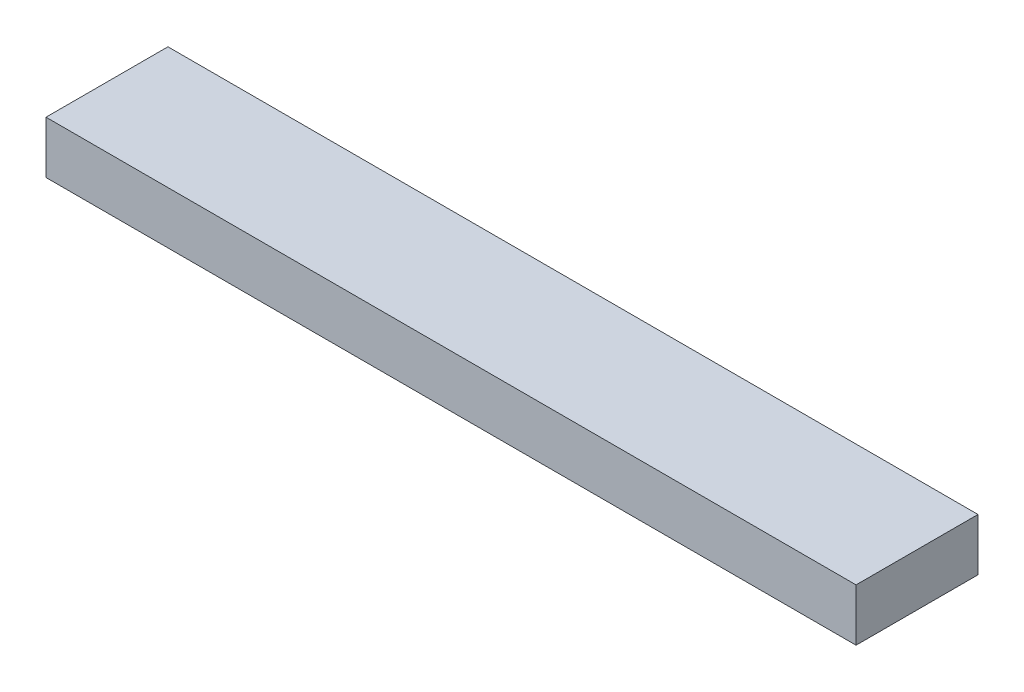
from build123d import *

# Parameters (mm, degrees)
SKETCH1_W           = 590.55
SKETCH1_H           = 88.9
BOSS_EXTRUDE1_DEPTH = 38.1


with BuildPart() as part:
    # Sketch1 → Boss-Extrude1 (new body)
    with BuildSketch(Plane(origin=(0, 0, 0), x_dir=(1, 0, 0), z_dir=(0, 1, 0))):
        with Locations((295.275, 44.45)):
            Rectangle(SKETCH1_W, SKETCH1_H)
    extrude(amount=BOSS_EXTRUDE1_DEPTH)


solid = part.part
